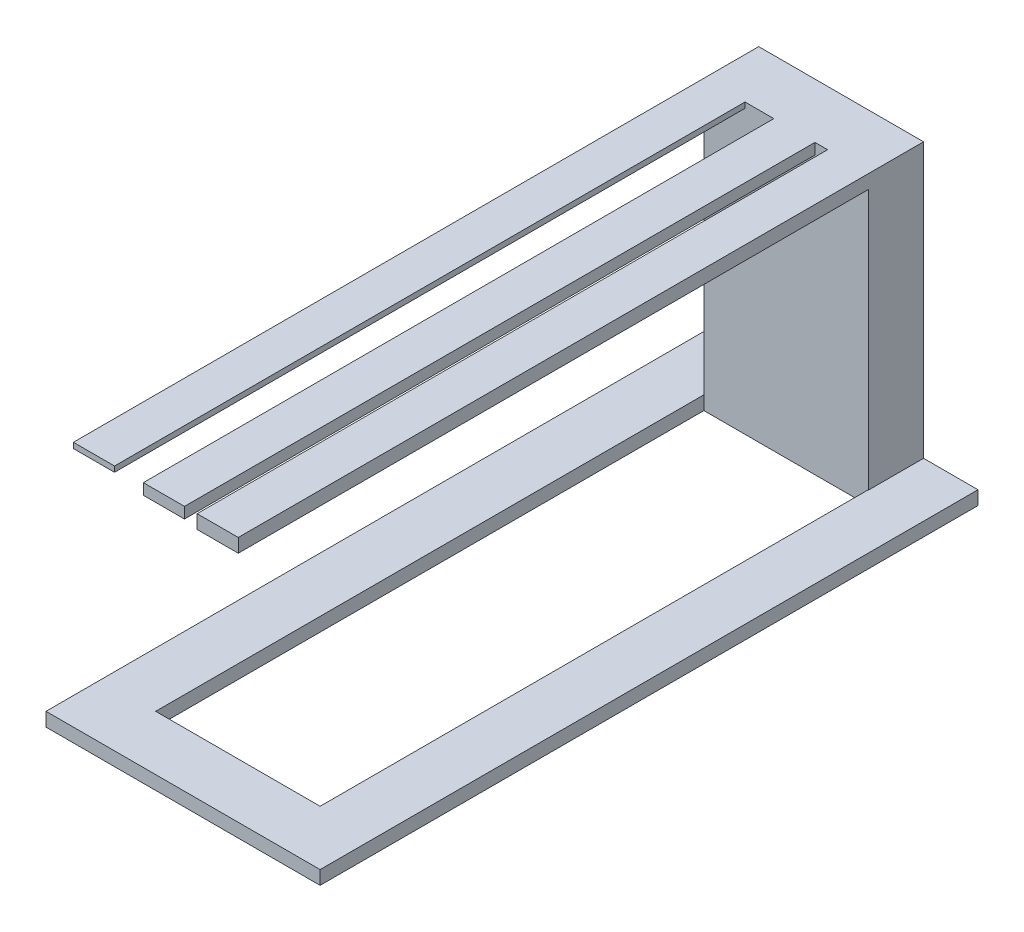
from build123d import *

# Parameters (mm, degrees)
SKETCH1_W           = 20
SKETCH1_H           = 20
BOSS_EXTRUDE1_DEPTH = 5
SKETCH2_W           = 60.136694628
SKETCH2_H           = 20
BOSS_EXTRUDE2_DEPTH = 100
SKETCH3_W           = 15
SKETCH3_H           = 2
SKETCH3_H_2         = 5
SKETCH3_H_3         = 4
BOSS_EXTRUDE3_DEPTH = 230


with BuildPart() as part:
    # Sketch1 → Boss-Extrude1 (new body)
    with BuildSketch(Plane(origin=(0, 0, 0), x_dir=(1, 0, 0), z_dir=(0, 1, 0))):
        Polygon((52.700369914, 19.481718454), (32.700369914, 19.481718454), (32.700369914, -180.518281546), (-27.299630086, -180.518281546), (-27.299630086, -200.518281546), (52.700369914, -200.518281546), align=None)
        Polygon((-27.299630086, 19.481718454), (32.700369914, 19.481718454), (52.700369914, 19.481718454), (52.700369914, 39.481718454), (-47.299630086, 39.481718454), (-47.299630086, -180.518281546), (-27.299630086, -180.518281546), align=None)
        with Locations((-37.299630086, -190.518281546)):
            Rectangle(SKETCH1_W, SKETCH1_H)
    extrude(amount=BOSS_EXTRUDE1_DEPTH)

    # Sketch2 → Boss-Extrude2 (add)
    with BuildSketch(Plane(origin=(0, 5, 0), x_dir=(1, 0, 0), z_dir=(0, 1, 0))):
        with Locations((2.768717228, 29.481718454)):
            Rectangle(SKETCH2_W, SKETCH2_H)
    extrude(amount=BOSS_EXTRUDE2_DEPTH)

    # Sketch3 → Boss-Extrude3 (add)
    with BuildSketch(Plane.XY.offset(-19.481718454)):
        with Locations((-19.799630086, 104)):
            Rectangle(SKETCH3_W, SKETCH3_H)
        with Locations((25.337064542, 102.5)):
            Rectangle(SKETCH3_W, SKETCH3_H_2)
        with Locations((5.71340039, 103)):
            Rectangle(SKETCH3_W, SKETCH3_H_3)
    extrude(amount=BOSS_EXTRUDE3_DEPTH)


solid = part.part
